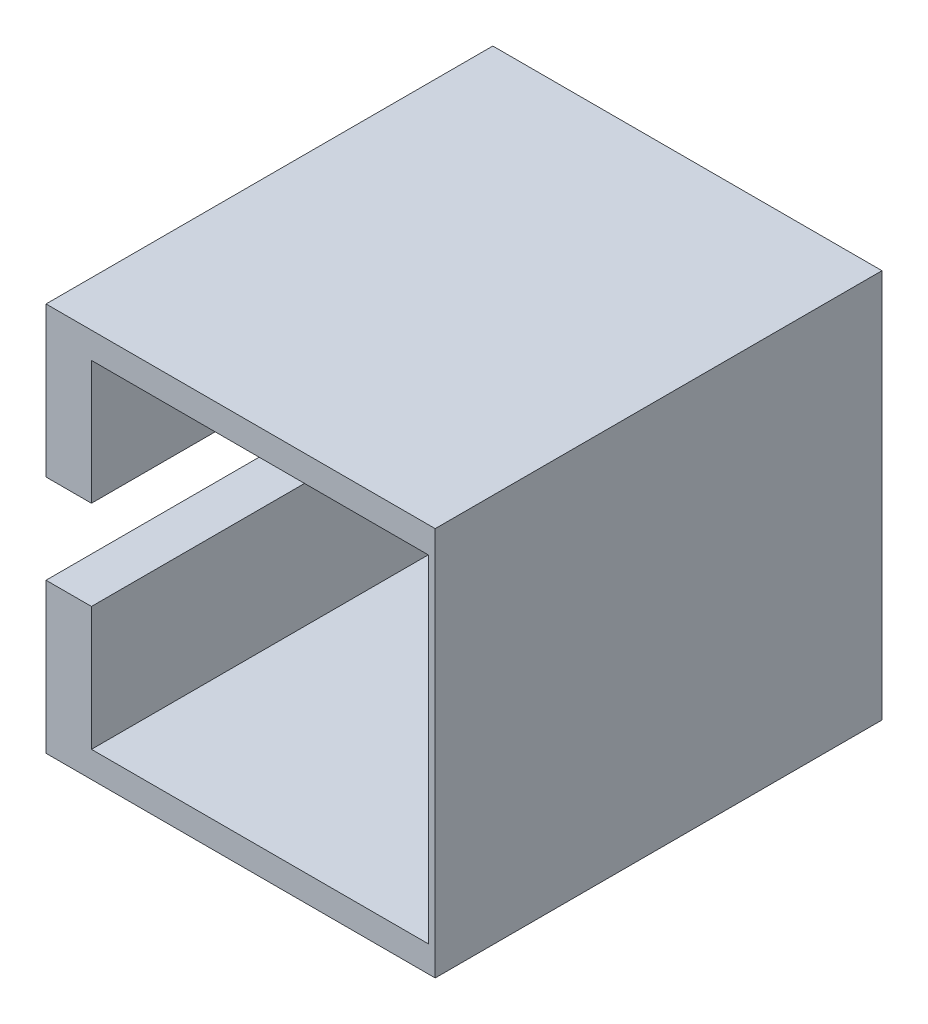
from build123d import *

# Parameters (mm, degrees)
SKETCH1_W           = 22.125
SKETCH1_H           = 22.125
SKETCH1_W_2         = 19.15
SKETCH1_H_2         = 19.15
BOSS_EXTRUDE1_DEPTH = 12.7
CUT_EXTRUDE1_DEPTH  = 12.7


with BuildPart() as part:
    # Sketch1 → Boss-Extrude1 (new body, symmetric)
    with BuildSketch(Plane.XY):
        with Locations((-2.278232981, -0.982857981)):
            Rectangle(SKETCH1_W, SKETCH1_H)
        with Locations((-1.182857981, -0.982857981)):
            Rectangle(SKETCH1_W_2, SKETCH1_H_2, mode=Mode.SUBTRACT)
    extrude(amount=BOSS_EXTRUDE1_DEPTH, both=True)

    # Sketch2 → Cut-Extrude1 (cut)
    with BuildSketch(Plane.ZY.offset(13.340732981)):
        with BuildLine():
            Line((-3.175, 1.557142019), (12.7, 1.557142019))
            Line((12.7, 1.557142019), (12.7, -3.522857981))
            Line((12.7, -3.522857981), (-3.175, -3.522857981))
            ThreePointArc((-3.175, -3.522857981), (-5.715, -0.982857981), (-3.175, 1.557142019))
        make_face()
    extrude(amount=-CUT_EXTRUDE1_DEPTH, mode=Mode.SUBTRACT)


solid = part.part
